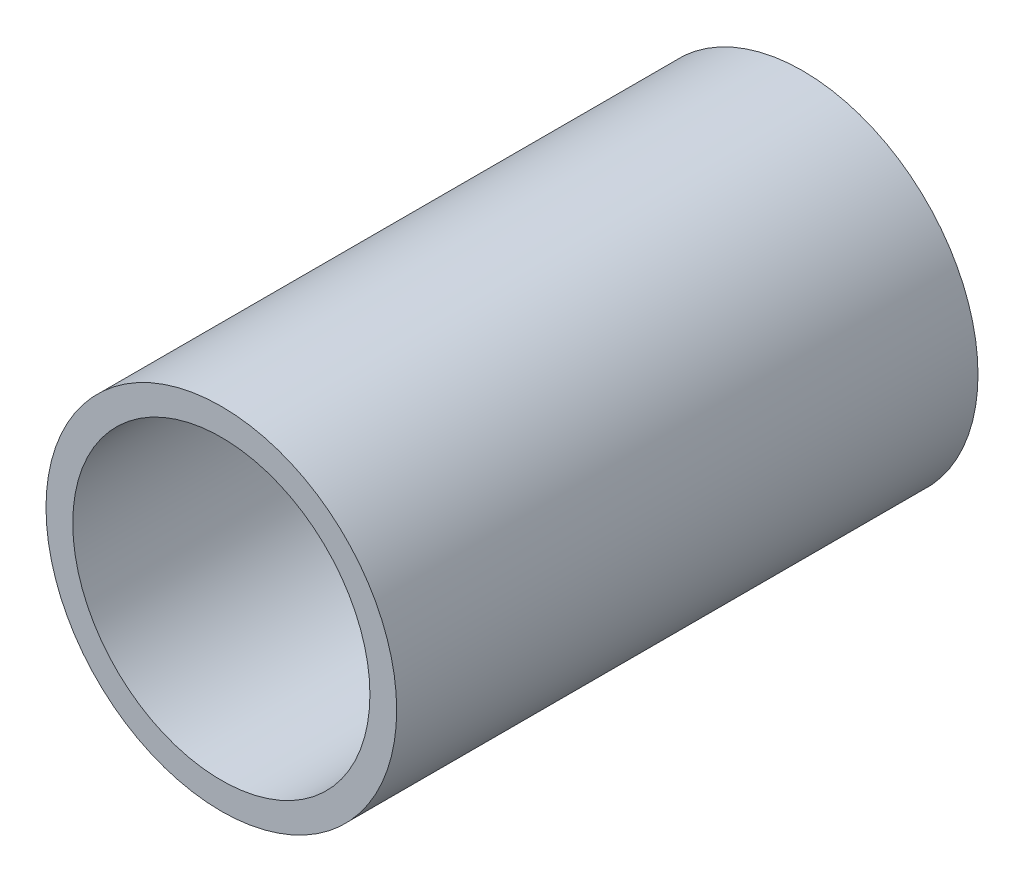
from build123d import *

# Parameters (mm, degrees)
SKETCH1_R           = 24.13
SKETCH1_R_2         = 20.447
EXTRUDE_THIN1_DEPTH = 40


with BuildPart() as part:
    # Sketch1 → Extrude-Thin1 (new body, symmetric)
    with BuildSketch(Plane.XY):
        Circle(SKETCH1_R)
        Circle(SKETCH1_R_2, mode=Mode.SUBTRACT)
    extrude(amount=EXTRUDE_THIN1_DEPTH, both=True)


solid = part.part
